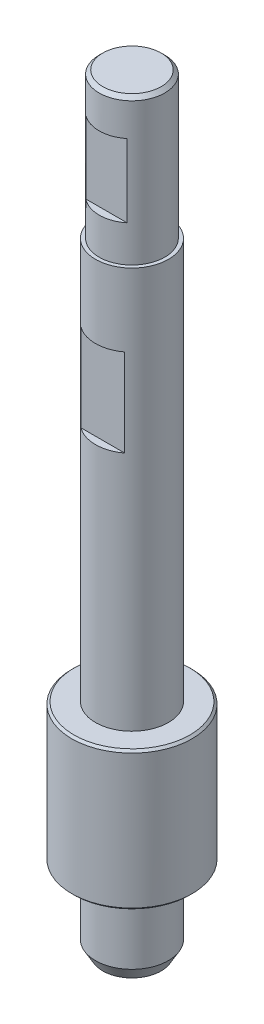
from build123d import *

# Parameters (mm, degrees)
CHANFREIN1_SIZE         = 1
CHANFREIN1_SIZE2        = 1.732050808
ESQUISSE3_W             = 48.532957324
ESQUISSE3_H             = 12
ENL_V_MAT_EXTRU_1_DEPTH = 1
ESQUISSE4_OUTSIDE_W     = 40.012
ESQUISSE4_OUTSIDE_H     = 40.012
ESQUISSE4_OUTSIDE_R     = 4.5
ENL_V_MAT_EXTRU_2_DEPTH = 20
ESQUISSE5_W             = 37.366082186
ESQUISSE5_H             = 10
ENL_V_MAT_EXTRU_3_DEPTH = 1.5
CHANFREIN2_SIZE         = 0.5
CHANFREIN3_SIZE         = 0.3


with BuildPart() as part:
    # Esquisse1 → Révolution1 (revolve)
    with BuildSketch(Plane.XY, mode=Mode.PRIVATE) as r_volution1_sk:
        Polygon((5, 73.557112482), (5, -1.442887518), (8.25, -1.442887518), (8.25, -20.442887518), (5, -20.442887518), (5, -31.442887518), (0, -31.442887518), (0, 73.557112482), align=None)
    revolve(r_volution1_sk.sketch.rotate(Axis((0, 73.557112482, 0), (0, -1, 0)), 180), axis=Axis((0, 73.557112482, 0), (0, -1, 0)))  # turned: the seam where the file's is

    # Chanfrein1
    chanfrein1_edges = [part.edges().sort_by_distance(p)[0] for p in [
        (5, -31.442887518, 0),
    ]]
    chanfrein1_side = [part.faces().sort_by_distance(p)[0] for p in [
        (0, -31.442887518, 0),
    ]]
    chamfer(chanfrein1_edges, length=CHANFREIN1_SIZE, length2=CHANFREIN1_SIZE2, reference=chanfrein1_side[0])

    # Esquisse3 → Enlèv. mat.-Extru.1 (cut)
    with BuildSketch(Plane.XY.offset(5)):
        with Locations((0, 37.557112482)):
            Rectangle(ESQUISSE3_W, ESQUISSE3_H)
    extrude(amount=-ENL_V_MAT_EXTRU_1_DEPTH, mode=Mode.SUBTRACT)

    # Esquisse4 outside → Enlèv. mat.-Extru.2 (cut)
    with BuildSketch(Plane(origin=(0, 73.557112482, 0), x_dir=(1, 0, 0), z_dir=(0, 1, 0))):
        Rectangle(ESQUISSE4_OUTSIDE_W, ESQUISSE4_OUTSIDE_H)
        with Locations(Location((0, 0, 0), (0, 0, 180))):  # turned: the seam where the file's is
            Circle(ESQUISSE4_OUTSIDE_R, mode=Mode.SUBTRACT)
    extrude(amount=-ENL_V_MAT_EXTRU_2_DEPTH, mode=Mode.SUBTRACT)

    # Esquisse5 → Enlèv. mat.-Extru.3 (cut)
    with BuildSketch(Plane.XY.offset(5)):
        with Locations((0, 63.557112482)):
            Rectangle(ESQUISSE5_W, ESQUISSE5_H)
    extrude(amount=-ENL_V_MAT_EXTRU_3_DEPTH, mode=Mode.SUBTRACT)

    # Chanfrein2
    chanfrein2_edges = [part.edges().sort_by_distance(p)[0] for p in [
        (4.5, 73.557112482, 0),
    ]]
    chamfer(chanfrein2_edges, length=CHANFREIN2_SIZE)

    # Chanfrein3
    chanfrein3_edges = [part.edges().sort_by_distance(p)[0] for p in [
        (8.25, -1.442887518, 0),
        (8.25, -20.442887518, 0),
    ]]
    chamfer(chanfrein3_edges, length=CHANFREIN3_SIZE)


solid = part.part
